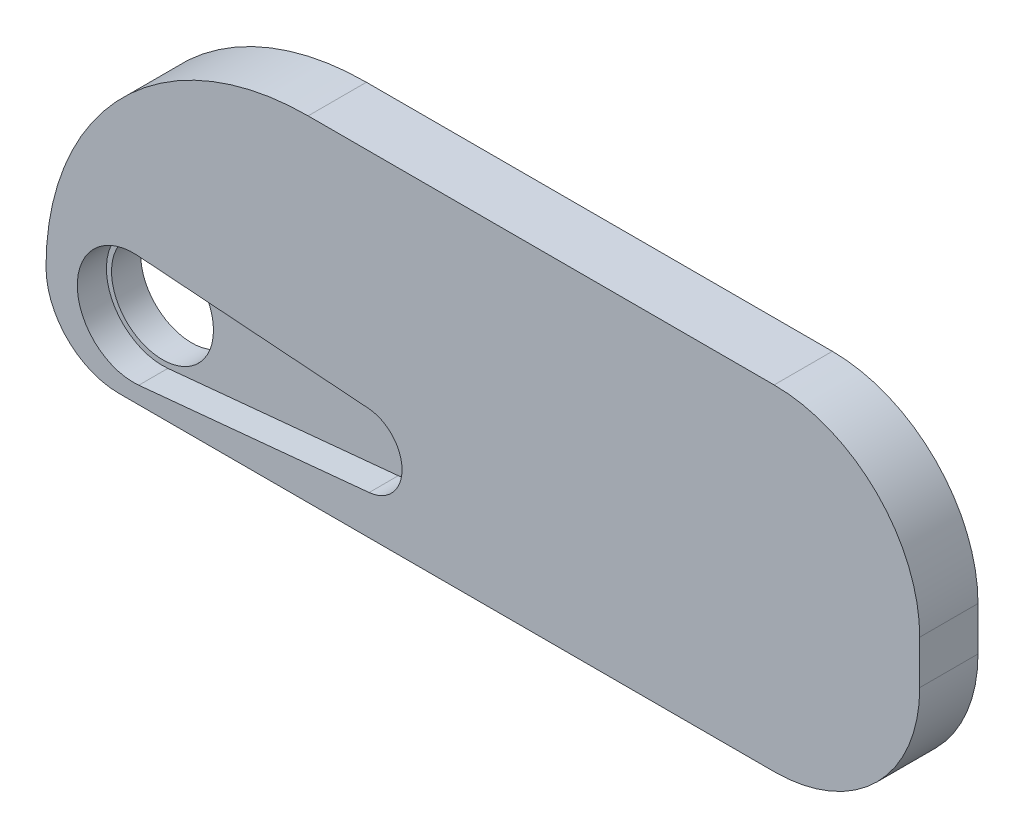
from build123d import *

# Parameters (mm, degrees)
SKIZZE6_W                       = 60
SKIZZE6_H                       = 23
AUFSATZ_LINEAR_AUSTRAGEN1_DEPTH = 4
SKIZZE7_R                       = 3.5
SCHNITT_LINEAR_AUSTRAGEN1_DEPTH = 5
VERRUNDUNG1_R                   = 10
SCHNITT_LINEAR_AUSTRAGEN2_DEPTH = 2
VERRUNDUNG2_R                   = 5
SCHNITT_LINEAR_AUSTRAGEN3_DEPTH = 5


with BuildPart() as part:
    # Skizze6 → Aufsatz-Linear austragen1 (new body)
    with BuildSketch(Plane.XY):
        with Locations((30, 6.5)):
            Rectangle(SKIZZE6_W, SKIZZE6_H)
    extrude(amount=AUFSATZ_LINEAR_AUSTRAGEN1_DEPTH)

    # Skizze7 → Schnitt-Linear austragen1 (cut, through all)
    with BuildSketch(Plane.XY.offset(4)):
        with Locations((6, 0)):
            Circle(SKIZZE7_R)
    extrude(amount=-SCHNITT_LINEAR_AUSTRAGEN1_DEPTH, mode=Mode.SUBTRACT)

    # Verrundung1
    verrundung1_edges = [part.edges().sort_by_distance(p)[0] for p in [
        (0, 18, 2),
        (60, 18, 2),
        (60, -5, 2),
    ]]
    fillet(verrundung1_edges, radius=VERRUNDUNG1_R)

    # Skizze9 → Schnitt-Linear austragen2 (cut)
    with BuildSketch(Plane.XY.offset(4)):
        with BuildLine():
            Line((6.281560008, 3.839690608), (22.131768578, 2.677413406))
            ThreePointArc((22.131768578, 2.677413406), (24.448770853, 0.212964842), (22.189275528, -2.304312884))
            Line((22.189275528, -2.304312884), (6.370120712, -3.83216788))
            ThreePointArc((6.370120712, -3.83216788), (2.150256489, -0.044439818), (6.281560008, 3.839690608))
        make_face()
    extrude(amount=-SCHNITT_LINEAR_AUSTRAGEN2_DEPTH, mode=Mode.SUBTRACT)

    # Verrundung2
    verrundung2_edges = [part.edges().sort_by_distance(p)[0] for p in [
        (0, -5, 2),
    ]]
    fillet(verrundung2_edges, radius=VERRUNDUNG2_R)

    # Skizze10 → Schnitt-Linear austragen3 (cut, through all)
    with BuildSketch(Plane.XY.offset(4)):
        with BuildLine():
            Line((18, 18), (0, 18))
            Line((0, 18), (0, 0))
            ThreePointArc((0, 0), (5.272077939, 12.727922061), (18, 18))
        make_face()
    extrude(amount=-SCHNITT_LINEAR_AUSTRAGEN3_DEPTH, mode=Mode.SUBTRACT)


solid = part.part
